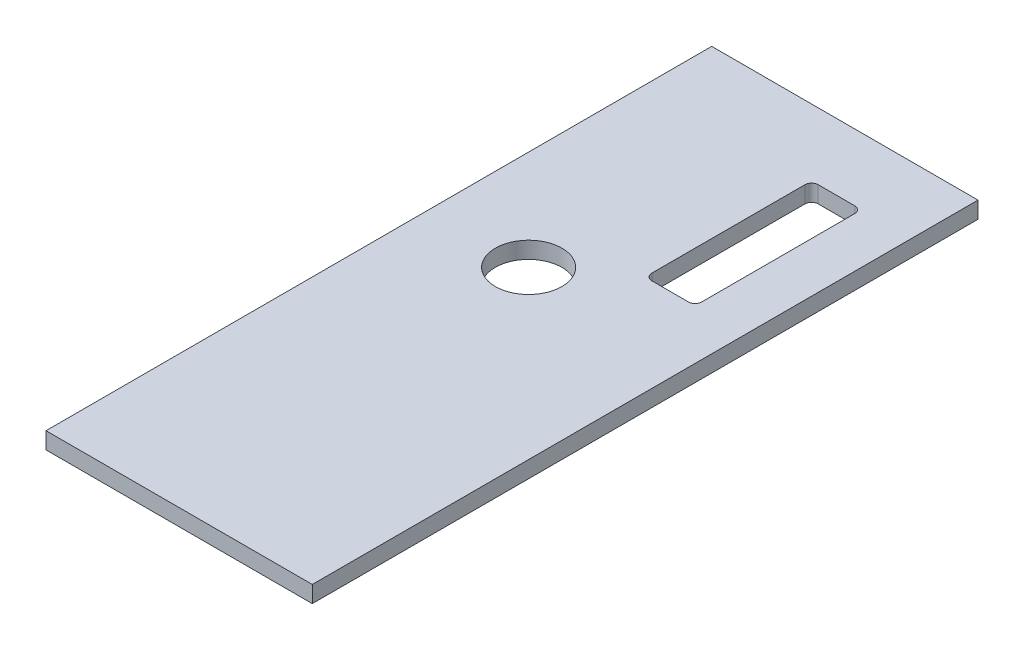
from build123d import *

# Parameters (mm, degrees)
SKETCH1_W           = 101.6
SKETCH1_H           = 254
SKETCH1_R           = 12.7
BOSS_EXTRUDE1_DEPTH = 6.35


with BuildPart() as part:
    # Sketch1 → Boss-Extrude1 (new body)
    with BuildSketch(Plane(origin=(0, 0, 0), x_dir=(1, 0, 0), z_dir=(0, 1, 0))):
        Rectangle(SKETCH1_W, SKETCH1_H)
        with Locations((-12.7, 19.05)):
            Circle(SKETCH1_R, mode=Mode.SUBTRACT)
        with BuildLine():
            Line((29.21, 101.6), (15.24, 101.6))
            ThreePointArc((15.24, 101.6), (13.443948776, 100.856051224), (12.7, 99.06))
            Line((12.7, 99.06), (12.7, 40.64))
            ThreePointArc((12.7, 40.64), (13.443948776, 38.843948776), (15.24, 38.1))
            Line((15.24, 38.1), (29.21, 38.1))
            ThreePointArc((29.21, 38.1), (31.006051224, 38.843948776), (31.75, 40.64))
            Line((31.75, 40.64), (31.75, 99.06))
            ThreePointArc((31.75, 99.06), (31.006051224, 100.856051224), (29.21, 101.6))
        make_face(mode=Mode.SUBTRACT)
    extrude(amount=BOSS_EXTRUDE1_DEPTH)


solid = part.part
